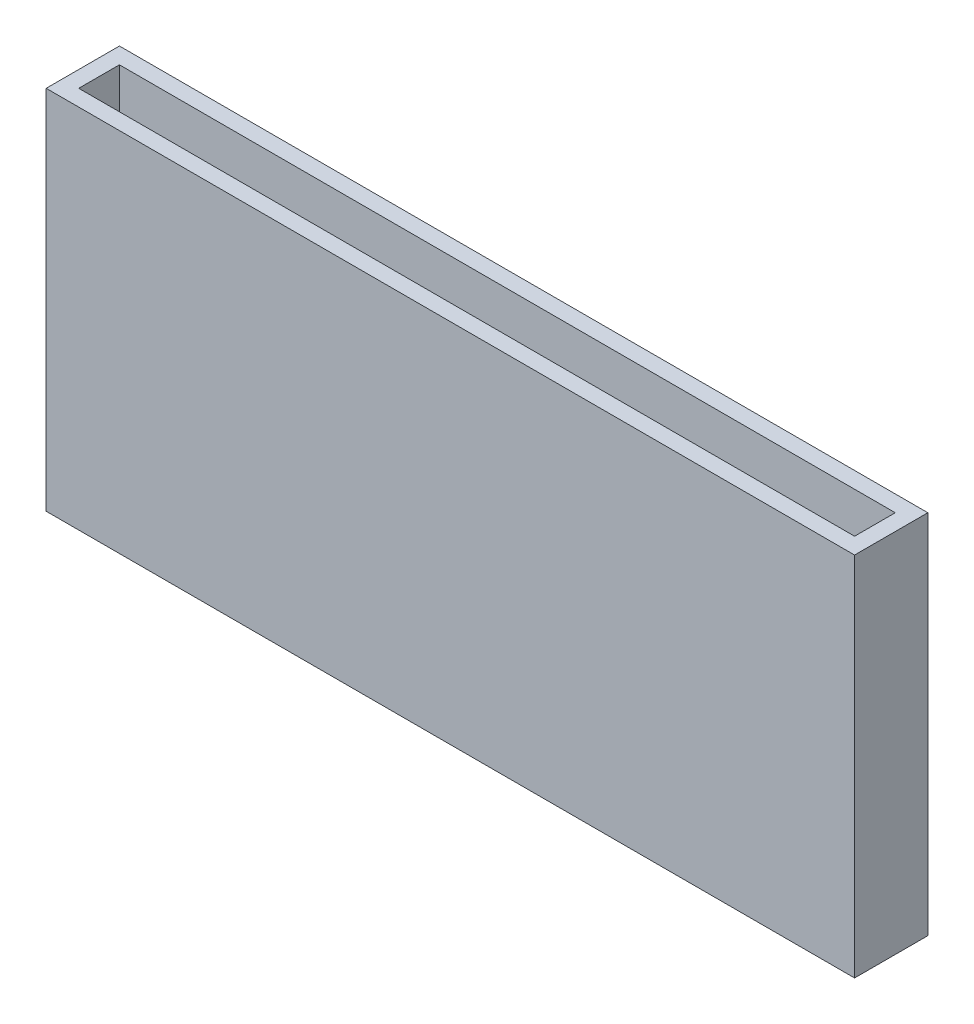
from build123d import *

# Parameters (mm, degrees)
SKETCH1_W           = 198.621366483
SKETCH1_H           = 90
BOSS_EXTRUDE1_DEPTH = 4
SKETCH3_W           = 4
SKETCH3_H           = 90
BOSS_EXTRUDE2_DEPTH = 10
SKETCH21_W          = 198.621366483
SKETCH21_H          = 90
BOSS_EXTRUDE3_DEPTH = 4


with BuildPart() as part:
    # Sketch1 → Boss-Extrude1 (new body)
    with BuildSketch(Plane.XY):
        with Locations((99.310683242, 45)):
            Rectangle(SKETCH1_W, SKETCH1_H)
    extrude(amount=BOSS_EXTRUDE1_DEPTH)

    # Sketch3 → Boss-Extrude2 (add)
    with BuildSketch(Plane.XY.offset(4)):
        with Locations((2, 45)):
            Rectangle(SKETCH3_W, SKETCH3_H)
        with Locations((196.621366483, 45)):
            Rectangle(SKETCH3_W, SKETCH3_H)
    extrude(amount=BOSS_EXTRUDE2_DEPTH)

    # Sketch21 → Boss-Extrude3 (add)
    with BuildSketch(Plane.XY.offset(14)):
        with Locations((99.310683242, 45)):
            Rectangle(SKETCH21_W, SKETCH21_H)
    extrude(amount=BOSS_EXTRUDE3_DEPTH)


solid = part.part
